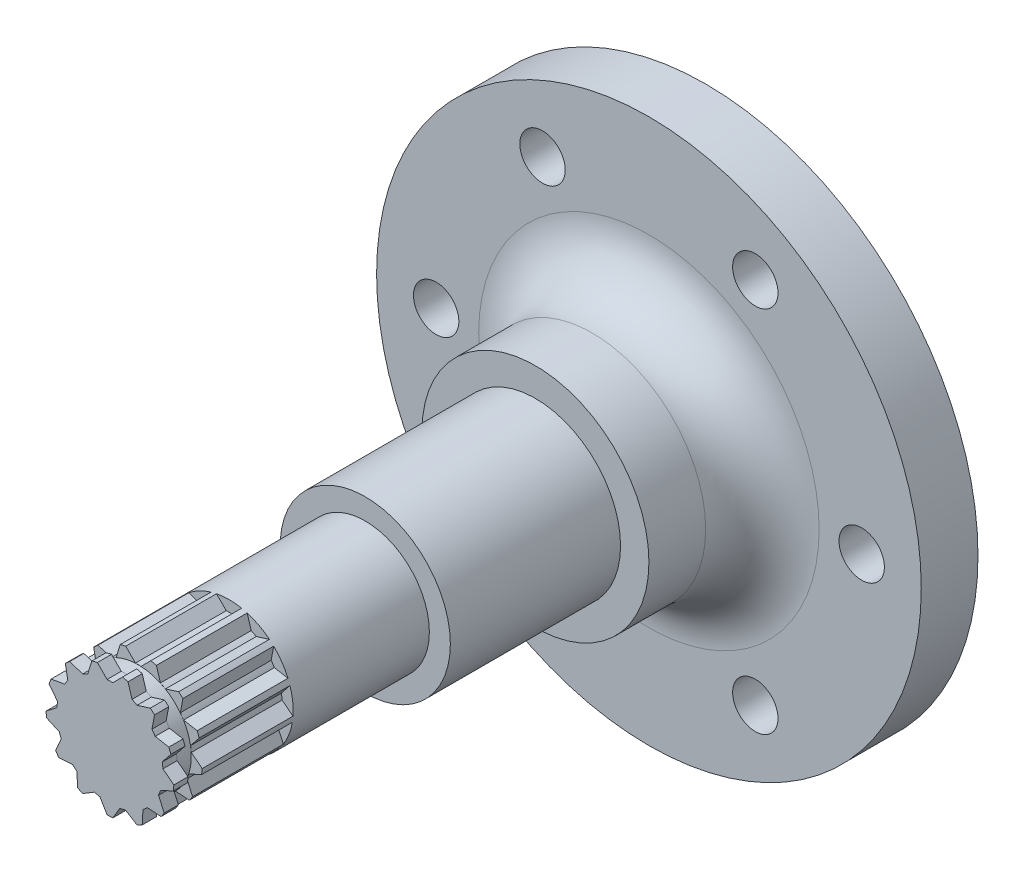
from build123d import *

# Parameters (mm, degrees)
SKETCH1_R           = 48
BOSS_EXTRUDE2_DEPTH = 10
SKETCH5_R           = 20
BOSS_EXTRUDE3_DEPTH = 30
SKETCH8_R           = 15
BOSS_EXTRUDE4_DEPTH = 30
SKETCH9_R           = 11.3
BOSS_EXTRUDE5_DEPTH = 45
SKETCH10_R          = 4
CUT_EXTRUDE1_DEPTH  = 45
FILLET1_R           = 10
CUT_EXTRUDE12_DEPTH = 21
SKETCH17_R          = 12.910346837
SKETCH17_R_2        = 9.35
CUT_EXTRUDE13_DEPTH = 2.5


with BuildPart() as part:
    # Sketch1 → Boss-Extrude2 (new body)
    with BuildSketch(Plane.XY):
        Circle(SKETCH1_R)
    extrude(amount=BOSS_EXTRUDE2_DEPTH)

    # Sketch5 → Boss-Extrude3 (add)
    with BuildSketch(Plane.XY):
        Circle(SKETCH5_R)
    extrude(amount=BOSS_EXTRUDE3_DEPTH)

    # Sketch8 → Boss-Extrude4 (add)
    with BuildSketch(Plane.XY.offset(30)):
        Circle(SKETCH8_R)
    extrude(amount=BOSS_EXTRUDE4_DEPTH)

    # Sketch9 → Boss-Extrude5 (add)
    with BuildSketch(Plane.XY.offset(60)):
        Circle(SKETCH9_R)
    extrude(amount=BOSS_EXTRUDE5_DEPTH)

    # Sketch10 → Cut-Extrude1 (cut)
    with BuildSketch(Plane.XY.offset(10)):
        with Locations((-37.5, 0)):
            Circle(SKETCH10_R)
        with Locations((-18.75, 32.475952642)):
            Circle(SKETCH10_R)
        with Locations((18.75, 32.475952642)):
            Circle(SKETCH10_R)
        with Locations((37.5, 0)):
            Circle(SKETCH10_R)
        with Locations((18.75, -32.475952642)):
            Circle(SKETCH10_R)
        with Locations((-18.75, -32.475952642)):
            Circle(SKETCH10_R)
    extrude(amount=-CUT_EXTRUDE1_DEPTH, mode=Mode.SUBTRACT)

    # Fillet1
    fillet1_edges = [part.edges().sort_by_distance(p)[0] for p in [
        (-20, 0, 10),
    ]]
    fillet(fillet1_edges, radius=FILLET1_R)

    # Sketch11 → Cut-Extrude12 (cut)
    with BuildSketch(Plane.XY.offset(105)):
        with BuildLine():
            Line((-10.377723879, 4.471336164), (-7.979912421, 4.901451086))
            ThreePointArc((-7.979912421, 4.901451086), (-7.707351037, 5.31977114), (-7.41288283, 5.722970658))
            Line((-7.41288283, 5.722970658), (-7.859673611, 8.118838016))
            ThreePointArc((-7.859673611, 8.118838016), (-9.29928676, 6.419755895), (-10.377723879, 4.471336164))
        make_face()
        with BuildLine():
            Line((-7.111084616, 8.781940309), (-4.788043642, 8.048469611))
            ThreePointArc((-4.788043642, 8.048469611), (-4.352299499, 8.292208034), (-3.904184691, 8.512377276))
            Line((-3.904184691, 8.512377276), (-3.186383203, 10.841446494))
            ThreePointArc((-3.186383203, 10.841446494), (-5.250700172, 10.006005582), (-7.111084616, 8.781940309))
        make_face()
        with BuildLine():
            Line((-2.215381565, 11.080707763), (-0.499291766, 9.351680744))
            ThreePointArc((-0.499291766, 9.351680744), (-0.000188596, 9.364999998), (0.498915109, 9.351700846))
            Line((0.498915109, 9.351700846), (2.216869197, 11.080410234))
            ThreePointArc((2.216869197, 11.080410234), (0.000758547, 11.299999975), (-2.215381565, 11.080707763))
        make_face()
        with BuildLine():
            ThreePointArc((3.903841837, 8.512534518), (4.351965512, 8.292383324), (4.787719471, 8.048662452))
            Line((4.787719471, 8.048662452), (7.112263581, 8.780985523))
            ThreePointArc((7.112263581, 8.780985523), (5.252043492, 10.005300553), (3.187838704, 10.841018605))
            Line((3.187838704, 10.841018605), (3.903841837, 8.512534518))
        make_face()
        with BuildLine():
            ThreePointArc((7.412652321, 5.723269221), (7.707136768, 5.320081564), (7.979715, 4.901772487))
            Line((7.979715, 4.901772487), (10.37832409, 4.469942851))
            ThreePointArc((10.37832409, 4.469942851), (9.300148567, 6.418507352), (7.860763544, 8.117782733))
            Line((7.860763544, 8.117782733), (7.412652321, 5.723269221))
        make_face()
        with BuildLine():
            ThreePointArc((9.22331349, 1.622871918), (9.296695871, 1.129013232), (9.343653989, 0.631945518))
            Line((9.343653989, 0.631945518), (11.266835622, -0.865109859))
            ThreePointArc((11.266835622, -0.865109859), (11.291705862, -0.432872656), (11.3, 0))
            ThreePointArc((11.3, 0), (11.157319766, 1.790032301), (10.732882188, 3.534860667))
            Line((10.732882188, 3.534860667), (9.22331349, 1.622871918))
        make_face()
        with BuildLine():
            ThreePointArc((8.921024692, -2.849305783), (8.756493988, -3.320698426), (8.567074452, -3.782652553))
            Line((8.567074452, -3.782652553), (9.574250893, -6.001976327))
            ThreePointArc((9.574250893, -6.001976327), (10.565414534, -4.007744468), (11.146226868, -1.857855378))
            Line((11.146226868, -1.857855378), (8.921024692, -2.849305783))
        make_face()
        with BuildLine():
            ThreePointArc((6.575036647, -6.668741867), (6.210284859, -7.009678093), (5.827881402, -7.33069051))
            Line((5.827881402, -7.33069051), (5.688320667, -9.76386235))
            ThreePointArc((5.688320667, -9.76386235), (7.492718241, -8.458674445), (9.006105299, -6.824959145))
            Line((9.006105299, -6.824959145), (6.575036647, -6.668741867))
        make_face()
        with BuildLine():
            ThreePointArc((2.722786944, -8.960449557), (2.241374312, -9.092824984), (1.753590957, -9.199355616))
            Line((1.753590957, -9.199355616), (0.499264728, -11.288965175))
            ThreePointArc((0.499264728, -11.288965175), (2.703530495, -10.971824044), (4.802793542, -10.228547023))
            Line((4.802793542, -10.228547023), (2.722786944, -8.960449557))
        make_face()
        with BuildLine():
            ThreePointArc((-4.804166743, -10.227902126), (-2.705003505, -10.97146098), (-0.500780336, -11.288898044))
            Line((-0.500780336, -11.288898044), (-1.753220435, -9.199426238))
            ThreePointArc((-1.753220435, -9.199426238), (-2.24100808, -9.092915252), (-2.722426043, -8.960559215))
            Line((-2.722426043, -8.960559215), (-4.804166743, -10.227902126))
        make_face()
        with BuildLine():
            Line((-5.689631474, -9.76309857), (-5.827586141, -7.330925233))
            ThreePointArc((-5.827586141, -7.330925233), (-6.210002527, -7.009928218), (-6.574768046, -6.669006683))
            Line((-6.574768046, -6.669006683), (-9.007021511, -6.823749959))
            ThreePointArc((-9.007021511, -6.823749959), (-7.493853802, -8.457668426), (-5.689631474, -9.76309857))
        make_face()
        with BuildLine():
            Line((-9.575056609, -6.000690871), (-8.566922092, -3.782997605))
            ThreePointArc((-8.566922092, -3.782997605), (-8.756360234, -3.321051107), (-8.920909924, -2.849665091))
            Line((-8.920909924, -2.849665091), (-11.146476196, -1.856358912))
            ThreePointArc((-11.146476196, -1.856358912), (-10.565952503, -4.006325961), (-9.575056609, -6.000690871))
        make_face()
        with BuildLine():
            Line((-11.266951667, -0.86359721), (-9.343679434, 0.631569185))
            ThreePointArc((-9.343679434, 0.631569185), (-9.296741337, 1.128638789), (-9.223378847, 1.622500431))
            Line((-9.223378847, 1.622500431), (-10.732407515, 3.53630159))
            ThreePointArc((-10.732407515, 3.53630159), (-11.217518819, 1.3628175), (-11.266951667, -0.86359721))
        make_face()
    extrude(amount=-CUT_EXTRUDE12_DEPTH, mode=Mode.SUBTRACT)

    # Sketch17 → Cut-Extrude13 (cut)
    with BuildSketch(Plane(origin=(0, 0, 100), x_dir=(-1, 0, 0), z_dir=(0, 0, -1))):
        Circle(SKETCH17_R)
        Circle(SKETCH17_R_2, mode=Mode.SUBTRACT)
    extrude(amount=-CUT_EXTRUDE13_DEPTH, mode=Mode.SUBTRACT)


solid = part.part
